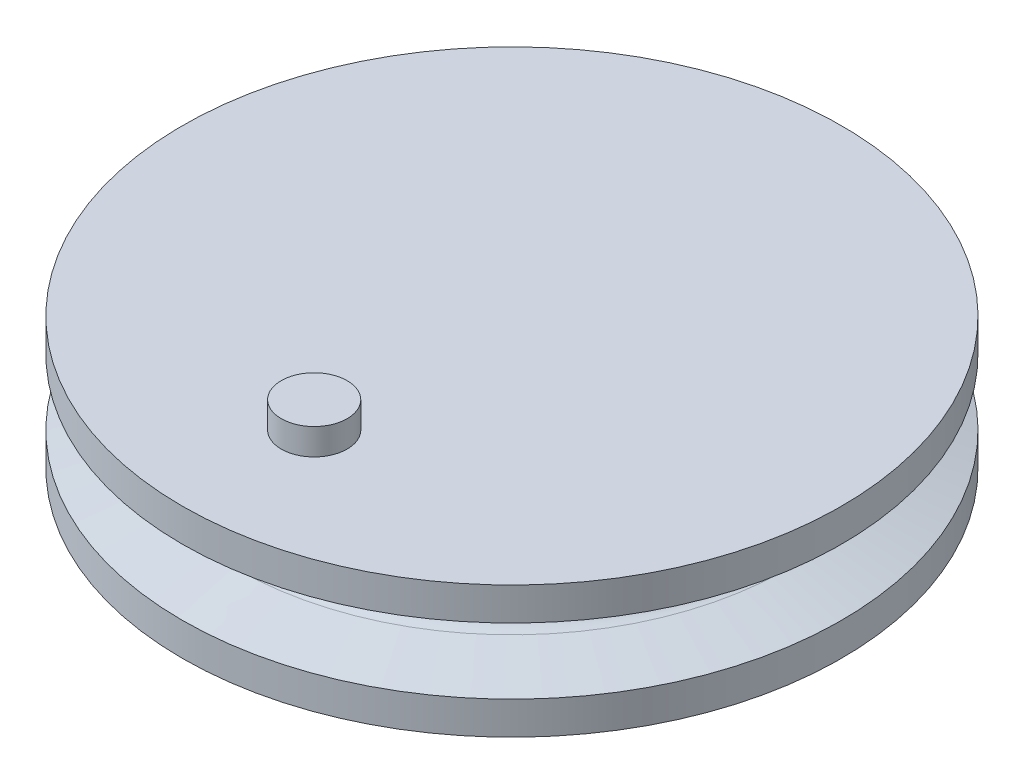
from build123d import *

# Parameters (mm, degrees)
SKETCH1_R           = 20
BOSS_EXTRUDE1_DEPTH = 10
SKETCH3_R           = 2.5
CUT_EXTRUDE1_DEPTH  = 5
SKETCH4_R           = 2.5
BOSS_EXTRUDE2_DEPTH = 2


with BuildPart() as part:
    # Sketch1 → Boss-Extrude1 (new body)
    with BuildSketch(Plane(origin=(0, 0, 0), x_dir=(1, 0, 0), z_dir=(0, 1, 0))):
        Circle(SKETCH1_R)
    extrude(amount=BOSS_EXTRUDE1_DEPTH)

    # Sketch2 → Revolve1 (revolve)
    with BuildSketch(Plane(origin=(0, 0, 0), x_dir=(0, 0, -1), z_dir=(1, 0, 0))):
        with BuildLine():
            Line((20, 10), (25, 10))
            Line((25, 10), (25, 7.5))
            Line((25, 7.5), (20.872288151, 6.191567774))
            ThreePointArc((20.872288151, 6.191567774), (20, 5), (20.872288151, 3.808432226))
            Line((20.872288151, 3.808432226), (25, 2.5))
            Line((25, 2.5), (25, 0))
            Line((25, 0), (20, 0))
            Line((20, 0), (19.25, 0))
            Line((19.25, 0), (19.25, 10))
            Line((19.25, 10), (20, 10))
        make_face()
    revolve(axis=Axis((0, 10, 0), (0, -1, 0)))

    # Sketch3 → Cut-Extrude1 (cut)
    with BuildSketch(Plane.XZ):
        Circle(SKETCH3_R)
    extrude(amount=-CUT_EXTRUDE1_DEPTH, mode=Mode.SUBTRACT)

    # Sketch4 → Boss-Extrude2 (add)
    with BuildSketch(Plane(origin=(0, 10, 0), x_dir=(1, 0, 0), z_dir=(0, 1, 0))):
        with Locations((0, -15)):
            Circle(SKETCH4_R)
    extrude(amount=BOSS_EXTRUDE2_DEPTH)


solid = part.part
